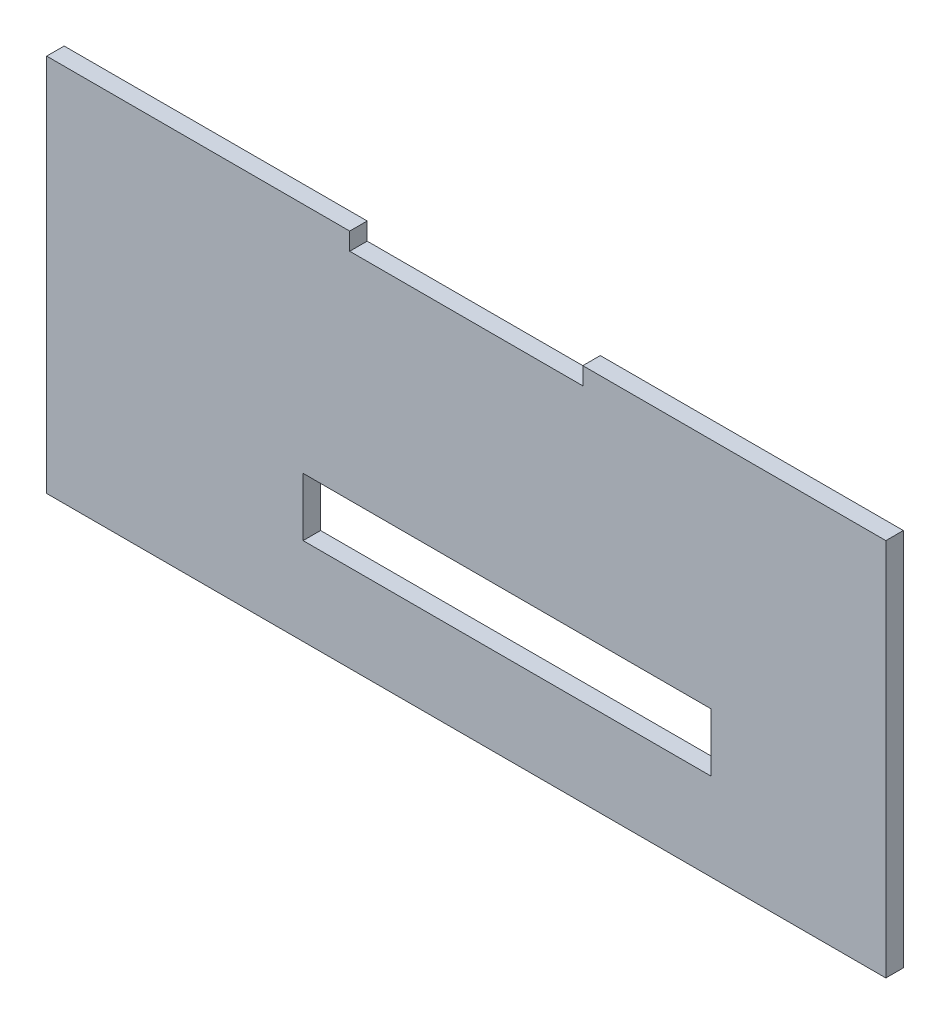
from build123d import *

# Parameters (mm, degrees)
ESBO_O1_W                     = 70
ESBO_O1_H                     = 10
RESSALTO_EXTRUS_O1_DEPTH      = 1
RESSALTO_EXTRUS_O1_DEPTH_BACK = 2


with BuildPart() as part:
    # Esboço1 → Ressalto-extrusão1 (new body, two sides)
    with BuildSketch(Plane.XY) as ressalto_extrus_o1_sk:
        Polygon((-68.286430173, 37.282901017), (-120.286430173, 37.282901017), (-120.286430173, -27.717098983), (23.713569827, -27.717098983), (23.713569827, 37.282901017), (-28.286430173, 37.282901017), (-28.286430173, 34.282901017), (-68.286430173, 34.282901017), align=None)
        with Locations((-41.286430173, -7.717098983)):
            Rectangle(ESBO_O1_W, ESBO_O1_H, mode=Mode.SUBTRACT)
    extrude(amount=RESSALTO_EXTRUS_O1_DEPTH)
    extrude(ressalto_extrus_o1_sk.sketch, amount=-RESSALTO_EXTRUS_O1_DEPTH_BACK)


solid = part.part
